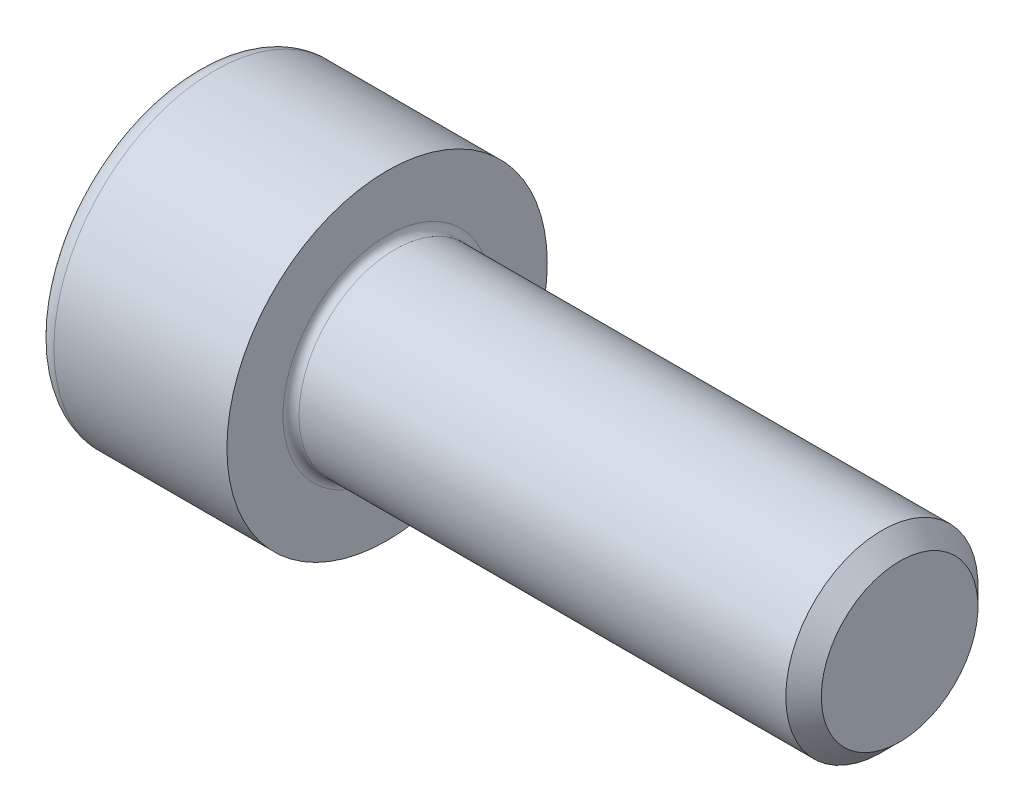
from build123d import *

# Parameters (mm, degrees)
FILLET1_R   = 0.25
FILLET2_R   = 0.6
HEX_2_DEPTH = 3


with BuildPart() as part:
    # BodySke → Base-Revolve (revolve)
    with BuildSketch(Plane.XY):
        Polygon((0, 0), (0, 5), (6, 5), (6, 3), (21.4455, 3), (22, 2.4455), (22, 0), align=None)
    revolve(axis=Axis((-31.75, 0, 0), (1, 0, 0)))

    # Fillet1
    fillet1_edges = [part.edges().sort_by_distance(p)[0] for p in [
        (6, -3, 0),
    ]]
    fillet(fillet1_edges, radius=FILLET1_R)

    # Fillet2
    fillet2_edges = [part.edges().sort_by_distance(p)[0] for p in [
        (0, -5, 0),
    ]]
    fillet(fillet2_edges, radius=FILLET2_R)

    # Sketch2 → Hex-PreBroach (revolve, cut)
    with BuildSketch(Plane.XY):
        Polygon((0, 2.51), (3, 2.51), (4.449149176, 0), (0, 0), align=None)
    revolve(axis=Axis((0, 0, 0), (1, 0, 0)), mode=Mode.SUBTRACT)

    # Sketch3 → Hex 2 (cut)
    with BuildSketch(Plane(origin=(0, 0, 0), x_dir=(0, 0.5, 0.866025404), z_dir=(-1, 0, 0))):
        Polygon((1.449149176, 2.51), (-1.449149176, 2.51), (-2.898298351, 0), (-1.449149176, -2.51), (1.449149176, -2.51), (2.898298351, 0), align=None)
    extrude(amount=-HEX_2_DEPTH, mode=Mode.SUBTRACT)


solid = part.part
